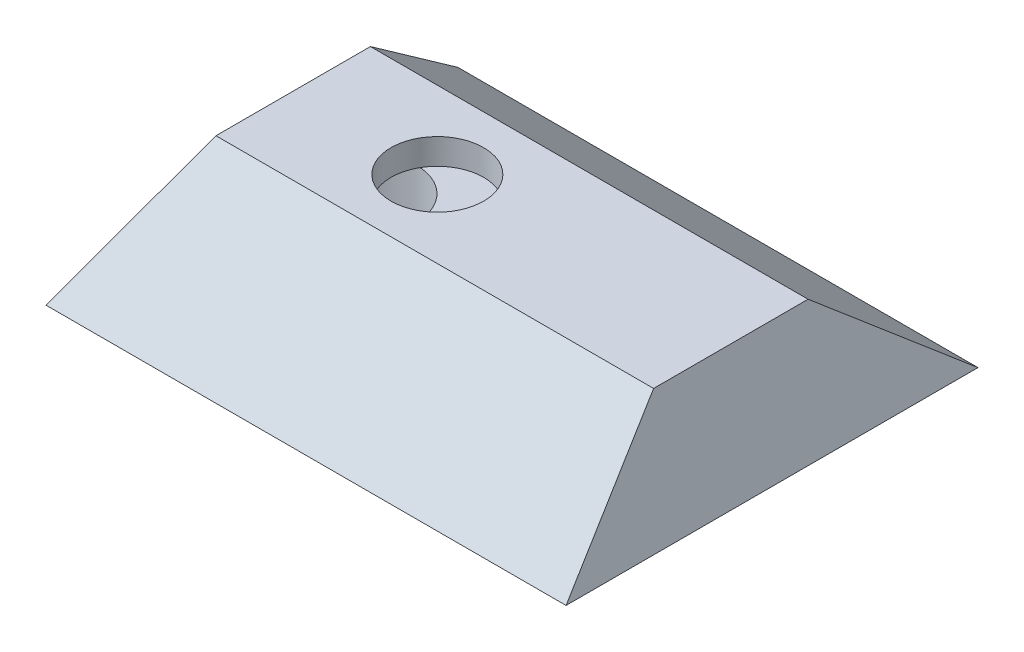
from build123d import *

# Parameters (mm, degrees)
SKETCH1_W                       = 85
SKETCH1_H                       = 30
BOSS_EXTRUDE1_DEPTH             = 20
BOSS_EXTRUDE2_DEPTH             = 85
BOSS_EXTRUDE3_REACH             = 42
BOSS_EXTRUDE3_DIRECTION_2_REACH = 42
SKETCH4_R                       = 3.5
CUT_EXTRUDE1_DEPTH              = 21
SKETCH5_R                       = 9
CUT_EXTRUDE2_DEPTH              = 5
BOSS_EXTRUDE4_DEPTH             = 9
SKETCH6_3_R                     = 9.5
CUT_EXTRUDE3_DEPTH              = 7
SKETCH6_4_R                     = 9.5
SKETCH6_4_R_2                   = 3.5
BOSS_EXTRUDE5_DEPTH             = 6
SKETCH8_R                       = 10
SKETCH8_R_2                     = 9.5
BOSS_EXTRUDE6_DEPTH             = 13
CUT_EXTRUDE4_DEPTH              = 5
CUT_EXTRUDE4_DEPTH_BACK         = 40
SKETCH10_W                      = 34.61835073
SKETCH10_H                      = 46.546399138
CUT_EXTRUDE5_DEPTH              = 6


with BuildPart() as part:
    # Sketch1 → Boss-Extrude1 (new body)
    with BuildSketch(Plane(origin=(0, 0, 0), x_dir=(1, 0, 0), z_dir=(0, 1, 0))):
        Rectangle(SKETCH1_W, SKETCH1_H)
    extrude(amount=BOSS_EXTRUDE1_DEPTH)

    # Sketch2 → Boss-Extrude2 (add)
    with BuildSketch(Plane(origin=(42.5, 0, 0), x_dir=(0, 0, -1), z_dir=(1, 0, 0))):
        Polygon((15, 20), (40, 0), (15, 0), align=None)
        Polygon((-15, 20), (-40, 0), (-15, 0), align=None)
    extrude(amount=-BOSS_EXTRUDE2_DEPTH)

    # Boss-Extrude3: up to this face of the body (flat: up to its plane)
    boss_extrude3_end = Plane(part.part.faces().sort_by_distance((0, 10, -27.5))[0])
    # Sketch3 → Boss-Extrude3 (add, up to the picked face)
    with BuildSketch(Plane.XY, mode=Mode.PRIVATE) as boss_extrude3_sk1:
        Polygon((42.5, 20), (50.5, 0), (42.5, 0), align=None)
    boss_extrude3_tool1 = split(extrude(boss_extrude3_sk1.sketch, amount=-BOSS_EXTRUDE3_REACH, mode=Mode.PRIVATE), bisect_by=boss_extrude3_end, keep=Keep.BOTH, mode=Mode.PRIVATE)
    add(boss_extrude3_tool1.solids().sort_by_distance((45.166667, 6.666667, 0))[0])
    # Sketch3 → Boss-Extrude3 (add, up to the picked face)
    with BuildSketch(Plane.XY, mode=Mode.PRIVATE) as boss_extrude3_sk2:
        Polygon((-42.5, 0), (-42.5, 20), (-50.5, 0), align=None)
    boss_extrude3_tool2 = split(extrude(boss_extrude3_sk2.sketch, amount=-BOSS_EXTRUDE3_REACH, mode=Mode.PRIVATE), bisect_by=boss_extrude3_end, keep=Keep.BOTH, mode=Mode.PRIVATE)
    add(boss_extrude3_tool2.solids().sort_by_distance((-45.166667, 6.666667, 0))[0])

    # Boss-Extrude3 direction 2: up to this face of the body (flat: up to its plane)
    boss_extrude3_direction_2_end = Plane(part.part.faces().sort_by_distance((0, 10, 27.5))[0])
    # Sketch3 → Boss-Extrude3 direction 2 (add, up to the picked face)
    with BuildSketch(Plane.XY, mode=Mode.PRIVATE) as boss_extrude3_direction_2_sk1:
        Polygon((42.5, 20), (50.5, 0), (42.5, 0), align=None)
    boss_extrude3_direction_2_tool1 = split(extrude(boss_extrude3_direction_2_sk1.sketch, amount=BOSS_EXTRUDE3_DIRECTION_2_REACH, mode=Mode.PRIVATE), bisect_by=boss_extrude3_direction_2_end, keep=Keep.BOTH, mode=Mode.PRIVATE)
    add(boss_extrude3_direction_2_tool1.solids().sort_by_distance((45.166667, 6.666667, 0))[0])
    # Sketch3 → Boss-Extrude3 direction 2 (add, up to the picked face)
    with BuildSketch(Plane.XY, mode=Mode.PRIVATE) as boss_extrude3_direction_2_sk2:
        Polygon((-42.5, 0), (-42.5, 20), (-50.5, 0), align=None)
    boss_extrude3_direction_2_tool2 = split(extrude(boss_extrude3_direction_2_sk2.sketch, amount=BOSS_EXTRUDE3_DIRECTION_2_REACH, mode=Mode.PRIVATE), bisect_by=boss_extrude3_direction_2_end, keep=Keep.BOTH, mode=Mode.PRIVATE)
    add(boss_extrude3_direction_2_tool2.solids().sort_by_distance((-45.166667, 6.666667, 0))[0])

    # Sketch4 → Cut-Extrude1 (cut, through all)
    with BuildSketch(Plane(origin=(0, 20, 0), x_dir=(1, 0, 0), z_dir=(0, 1, 0))):
        with Locations((-14.5, 0)):
            Circle(SKETCH4_R)
    extrude(amount=-CUT_EXTRUDE1_DEPTH, mode=Mode.SUBTRACT)

    # Sketch5 → Cut-Extrude2 (cut)
    with BuildSketch(Plane(origin=(0, 20, 0), x_dir=(1, 0, 0), z_dir=(0, 1, 0))):
        with Locations((-14.5, 0)):
            Circle(SKETCH5_R)
    extrude(amount=-CUT_EXTRUDE2_DEPTH, mode=Mode.SUBTRACT)

    # Sketch6 → Boss-Extrude4 (add)
    with BuildSketch(Plane.XZ):
        with BuildLine():
            Line((-7.5, 5), (-32.968954756, 8.36635465))
            ThreePointArc((-32.968954756, 8.36635465), (-50.488194155, -7.60484858), (-31.776786955, -22.161164126))
            Line((-31.776786955, -22.161164126), (-7.5, -17))
            Line((-7.5, -17), (-7.5, 5))
        make_face()
        with BuildLine():
            ThreePointArc((-33.23102511, 6.383599211), (-48.48971749, -7.526803602), (-32.192685412, -20.204884884))
            Line((-32.192685412, -20.204884884), (-9.5, -15.380495475))
            Line((-9.5, -15.380495475), (-9.5, 3.246955109))
            Line((-9.5, 3.246955109), (-33.23102511, 6.383599211))
        make_face(mode=Mode.SUBTRACT)
    extrude(amount=BOSS_EXTRUDE4_DEPTH)

    # Sketch6_3 → Cut-Extrude3 (cut)
    with BuildSketch(Plane.XZ):
        with Locations((-35, -7)):
            Circle(SKETCH6_3_R)
    extrude(amount=-CUT_EXTRUDE3_DEPTH, mode=Mode.SUBTRACT)

    # Sketch6_4 → Boss-Extrude5 (add)
    with BuildSketch(Plane.XZ):
        with BuildLine():
            Line((-9.5, 3.246955109), (-33.23102511, 6.383599211))
            ThreePointArc((-33.23102511, 6.383599211), (-48.48971749, -7.526803602), (-32.192685412, -20.204884884))
            Line((-32.192685412, -20.204884884), (-9.5, -15.380495475))
            Line((-9.5, -15.380495475), (-9.5, 3.246955109))
        make_face()
        with Locations((-35, -7)):
            Circle(SKETCH6_4_R, mode=Mode.SUBTRACT)
        with Locations((-14.5, 0)):
            Circle(SKETCH6_4_R_2, mode=Mode.SUBTRACT)
    extrude(amount=BOSS_EXTRUDE5_DEPTH)

    # Sketch8 → Boss-Extrude6 (add)
    with BuildSketch(Plane.XZ.offset(6)):
        with Locations((-35, -7)):
            Circle(SKETCH8_R)
        with Locations((-35, -7)):
            Circle(SKETCH8_R_2, mode=Mode.SUBTRACT)
    extrude(amount=BOSS_EXTRUDE6_DEPTH)

    # Sketch9 → Cut-Extrude4 (cut, two sides)
    with BuildSketch(Plane(origin=(0, 0, 0), x_dir=(0, 0, -1), z_dir=(1, 0, 0))) as cut_extrude4_sk:
        Polygon((33.848828411, 3), (-33.848828411, 3), (-18.848828411, 15), (18.848828411, 15), align=None)
    extrude(amount=CUT_EXTRUDE4_DEPTH, mode=Mode.SUBTRACT)
    extrude(cut_extrude4_sk.sketch, amount=-CUT_EXTRUDE4_DEPTH_BACK, mode=Mode.SUBTRACT)

    # Sketch10 → Cut-Extrude5 (cut)
    with BuildSketch(Plane(origin=(0, 0, 0), x_dir=(-1, 0, 0), z_dir=(0, -1, 0))):
        with Locations((-25.663362502, 2.40647956)):
            Rectangle(SKETCH10_W, SKETCH10_H)
    extrude(amount=-CUT_EXTRUDE5_DEPTH, mode=Mode.SUBTRACT)


solid = part.part
